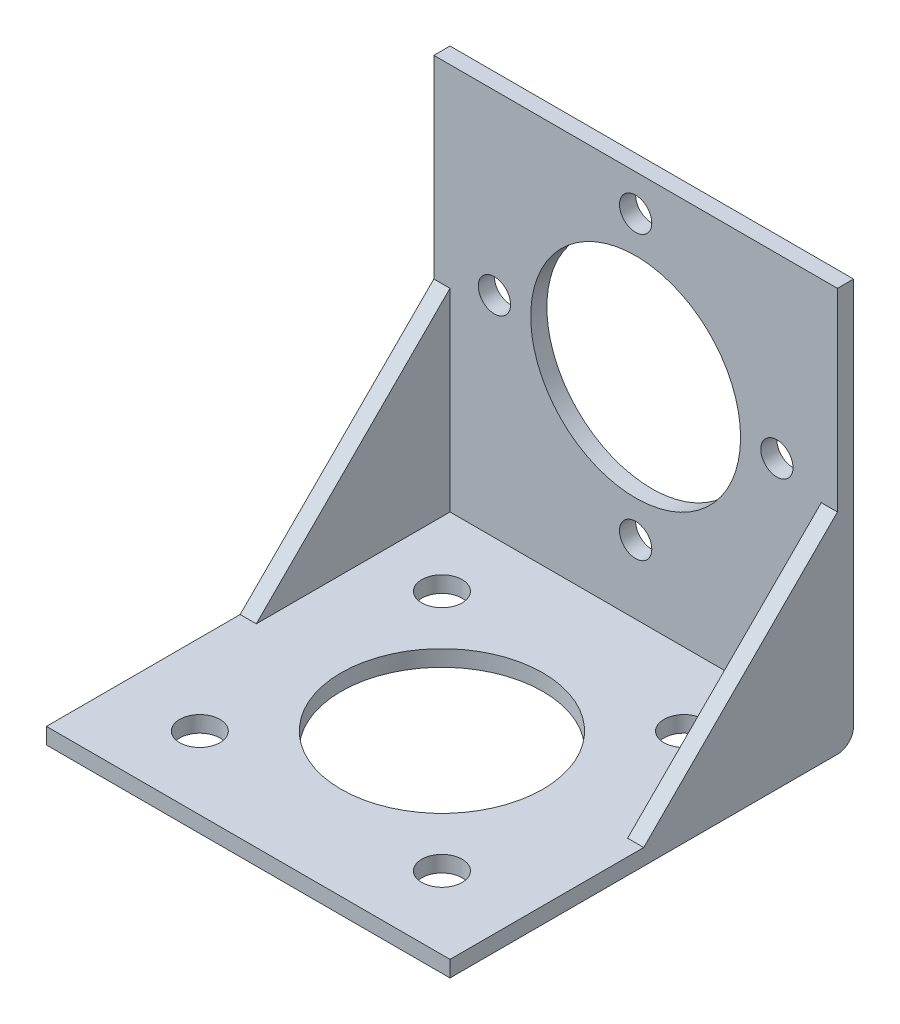
from build123d import *

# Parameters (mm, degrees)
EXTRUDE_1_DEPTH     = 50
EXTRUDE_2_DEPTH     = 2
EXTRUDE_4_DEPTH     = 2
SKETCH_4_R          = 13
SKETCH_4_R_2        = 2
CUT_EXTRUDE_1_DEPTH = 3
SKETCH_5_R          = 12.5
SKETCH_5_R_2        = 2.5
CUT_EXTRUDE_2_DEPTH = 3
FILLET_2_R          = 2


with BuildPart() as part:
    # 草图1 → 凸台-拉伸1 (new body)
    with BuildSketch(Plane(origin=(0, 0, 0), x_dir=(0, 0, -1), z_dir=(1, 0, 0))):
        Polygon((0, 0), (0, 50), (-2, 50), (-2, 2), (-50, 2), (-50, 0), align=None)
    extrude(amount=EXTRUDE_1_DEPTH)

    # 草图2 → 凸台-拉伸2 (add)
    with BuildSketch(Plane(origin=(50, 0, 0), x_dir=(0, 0, -1), z_dir=(1, 0, 0))):
        Polygon((-2, 26), (-26, 2), (-2, 2), align=None)
    extrude(amount=-EXTRUDE_2_DEPTH)

    # 草图3 → 凸台-拉伸4 (add)
    with BuildSketch(Plane.ZY):
        Polygon((2, 26), (26, 2), (2, 2), align=None)
    extrude(amount=-EXTRUDE_4_DEPTH)

    # 草图4 → 切除-拉伸1 (cut, through all)
    with BuildSketch(Plane.XY.offset(2)):
        with Locations((25, 28)):
            Circle(SKETCH_4_R)
        with Locations((25, 45.5)):
            Circle(SKETCH_4_R_2)
        with Locations((42.5, 28)):
            Circle(SKETCH_4_R_2)
        with Locations((25, 10.5)):
            Circle(SKETCH_4_R_2)
        with Locations((7.5, 28)):
            Circle(SKETCH_4_R_2)
    extrude(amount=-CUT_EXTRUDE_1_DEPTH, mode=Mode.SUBTRACT)

    # 草图5 → 切除-拉伸2 (cut, through all)
    with BuildSketch(Plane(origin=(0, 2, 0), x_dir=(1, 0, 0), z_dir=(0, 1, 0))):
        with Locations((25, -26)):
            Circle(SKETCH_5_R)
        with Locations((10, -11)):
            Circle(SKETCH_5_R_2)
        with Locations((40, -11)):
            Circle(SKETCH_5_R_2)
        with Locations((40, -41)):
            Circle(SKETCH_5_R_2)
        with Locations((10, -41)):
            Circle(SKETCH_5_R_2)
    extrude(amount=-CUT_EXTRUDE_2_DEPTH, mode=Mode.SUBTRACT)

    # 圆角2
    fillet_2_edges = [part.edges().sort_by_distance(p)[0] for p in [
        (25, 0, 0),
    ]]
    fillet(fillet_2_edges, radius=FILLET_2_R)


solid = part.part
